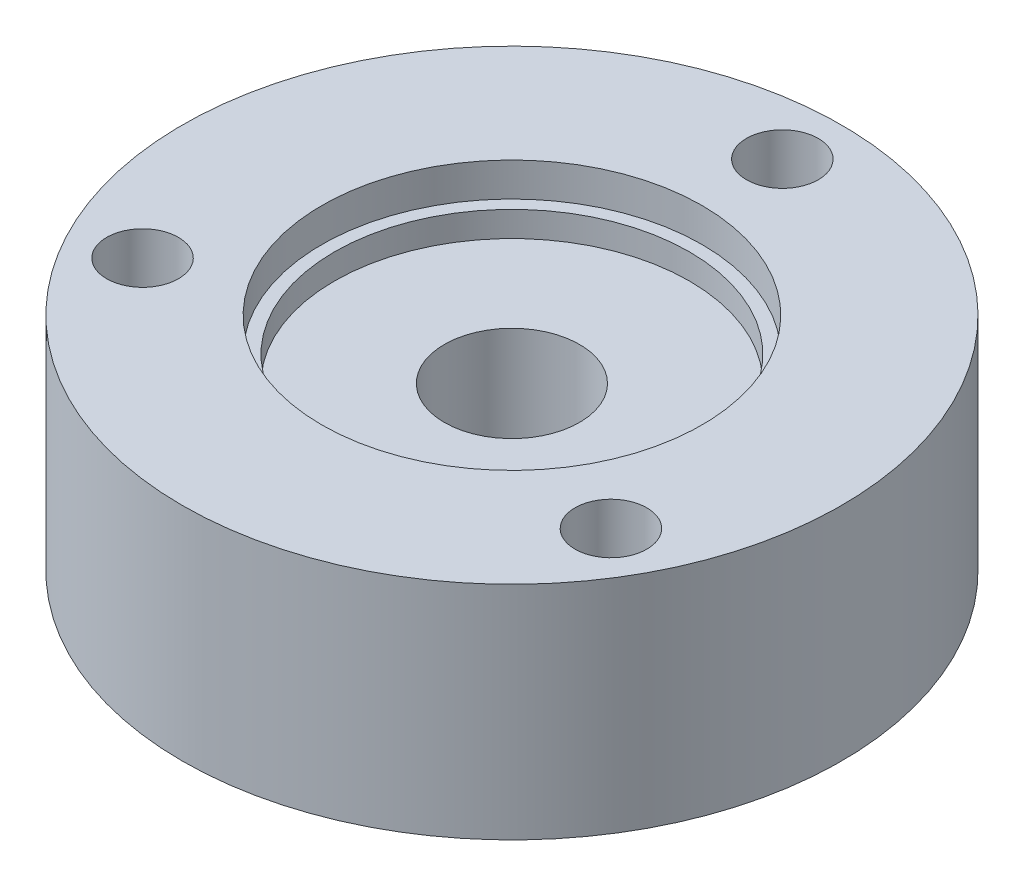
from build123d import *

# Parameters (mm, degrees)
SKETCH1_R               = 61.9125
BASE_EXTRUDE_DEPTH      = 7.9248
BASE_EXTRUDE_DEPTH_BACK = 33.6677
SKETCH11_R              = 33.3375
CUT_EXTRUDE1_DEPTH      = 9.525
SKETCH12_R              = 35.7124
CUT_EXTRUDE2_DEPTH      = 2.5748
CUT_EXTRUDE2_DEPTH_BACK = 4.7752
SKETCH13_R              = 12.7
CUT_EXTRUDE3_DEPTH      = 41.0177
SKETCH32_R              = 6.7437
CUT_EXTRUDE4_DEPTH      = 45.72


with BuildPart() as part:
    # Sketch1 → Base-Extrude (new body, two sides)
    with BuildSketch(Plane(origin=(0, 0, 0), x_dir=(1, 0, 0), z_dir=(0, 1, 0))) as base_extrude_sk:
        with Locations(Location((0, 0, 0), (0, 0, 270))):  # turned: the seam where the file's is
            Circle(SKETCH1_R)
    extrude(amount=BASE_EXTRUDE_DEPTH)
    extrude(base_extrude_sk.sketch, amount=-BASE_EXTRUDE_DEPTH_BACK)

    # Sketch11 → Cut-Extrude1 (cut)
    with BuildSketch(Plane(origin=(0, 6.35, 0), x_dir=(-1, 0, 0), z_dir=(0, 1, 0))):
        with Locations(Location((0, 0, 0), (0, 0, 90))):  # turned: the seam where the file's is
            Circle(SKETCH11_R)
    extrude(amount=-CUT_EXTRUDE1_DEPTH, mode=Mode.SUBTRACT)

    # Sketch12 → Cut-Extrude2 (cut, two sides)
    with BuildSketch(Plane(origin=(0, 6.35, 0), x_dir=(-1, 0, 0), z_dir=(0, 1, 0))) as cut_extrude2_sk:
        with Locations(Location((0, 0, 0), (0, 0, 90))):  # turned: the seam where the file's is
            Circle(SKETCH12_R)
    extrude(amount=CUT_EXTRUDE2_DEPTH, mode=Mode.SUBTRACT)
    extrude(cut_extrude2_sk.sketch, amount=-CUT_EXTRUDE2_DEPTH_BACK, mode=Mode.SUBTRACT)

    # Sketch13 → Cut-Extrude3 (cut, through all)
    with BuildSketch(Plane(origin=(0, 6.35, 0), x_dir=(-1, 0, 0), z_dir=(0, 1, 0))):
        with Locations(Location((0, 0, 0), (0, 0, 90))):  # turned: the seam where the file's is
            Circle(SKETCH13_R)
    extrude(amount=-CUT_EXTRUDE3_DEPTH, mode=Mode.SUBTRACT)

    # Sketch32 → Cut-Extrude4 (cut)
    with BuildSketch(Plane(origin=(0, 7.9248, 0), x_dir=(-1, 0, 0), z_dir=(0, 1, 0))):
        with Locations(Location((0, -50.8, 0), (0, 0, 90))):  # turned: the seam where the file's is
            Circle(SKETCH32_R)
        with Locations(Location((-43.994090512, 25.4, 0), (0, 0, 90))):  # turned: the seam where the file's is
            Circle(SKETCH32_R)
        with Locations(Location((43.994090512, 25.4, 0), (0, 0, 90))):  # turned: the seam where the file's is
            Circle(SKETCH32_R)
    extrude(amount=-CUT_EXTRUDE4_DEPTH, mode=Mode.SUBTRACT)


solid = part.part
